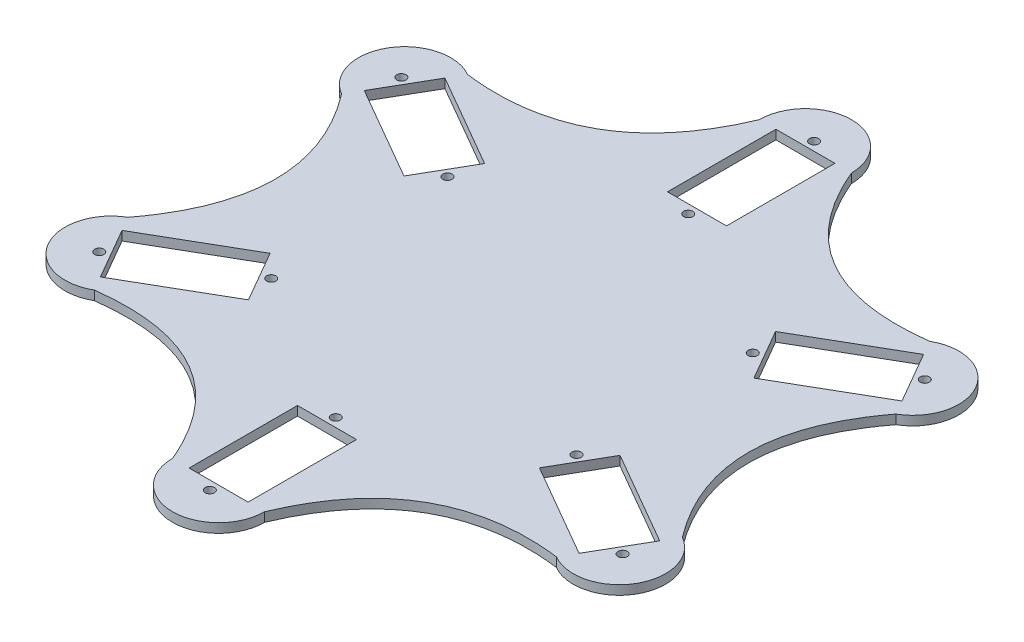
from build123d import *

# Parameters (mm, degrees)
SKETCH4_W           = 12.8
SKETCH4_H           = 23.5
SKETCH4_R           = 1
BOSS_EXTRUDE3_DEPTH = 2


with BuildPart() as part:
    # Sketch4 → Boss-Extrude3 (new body)
    with BuildSketch(Plane(origin=(0, 0, 0), x_dir=(1, 0, 0), z_dir=(0, 1, 0))):
        with BuildLine():
            ThreePointArc((10, 63.612159322), (0, 73.612159322), (-10, 63.612159322))
            add(Edge.make_bspline(
                [(-10, 63.612159322), (-21.25, 36.806079661), (-50.089745962, 40.466333699)],
                knots=[0, 0, 0, 1, 1, 1], degree=2))
            ThreePointArc((-50.089745962, 40.466333699), (-63.75, 36.806079661), (-60.089745962, 23.145825623))
            add(Edge.make_bspline(
                [(-60.089745962, 23.145825623), (-42.5, 0), (-60.089745962, -23.145825623)],
                knots=[0, 0, 0, 1, 1, 1], degree=2))
            ThreePointArc((-60.089745962, -23.145825623), (-63.75, -36.806079661), (-50.089745962, -40.466333699))
            add(Edge.make_bspline(
                [(-50.089745962, -40.466333699), (-21.25, -36.806079661), (-10, -63.612159322)],
                knots=[0, 0, 0, 1, 1, 1], degree=2))
            ThreePointArc((-10, -63.612159322), (0, -73.612159322), (10, -63.612159322))
            add(Edge.make_bspline(
                [(10, -63.612159322), (21.25, -36.806079661), (50.089745962, -40.466333699)],
                knots=[0, 0, 0, 1, 1, 1], degree=2))
            ThreePointArc((50.089745962, -40.466333699), (63.75, -36.806079661), (60.089745962, -23.145825623))
            add(Edge.make_bspline(
                [(60.089745962, -23.145825623), (42.5, 0), (60.089745962, 23.145825623)],
                knots=[0, 0, 0, 1, 1, 1], degree=2))
            ThreePointArc((60.089745962, 23.145825623), (63.75, 36.806079661), (50.089745962, 40.466333699))
            add(Edge.make_bspline(
                [(50.089745962, 40.466333699), (21.25, 36.806079661), (10, 63.612159322)],
                knots=[0, 0, 0, 1, 1, 1], degree=2))
        make_face()
        with Locations((0, 51.862159322)):
            Rectangle(SKETCH4_W, SKETCH4_H, mode=Mode.SUBTRACT)
        with Locations((0, 65.512159322)):
            Circle(SKETCH4_R, mode=Mode.SUBTRACT)
        Polygon((31.538148973, 25.598642245), (51.889745962, 37.348642245), (58.289745962, 26.263517077), (37.938148973, 14.513517077), align=None, mode=Mode.SUBTRACT)
        Polygon((37.938148973, -14.513517077), (58.289745962, -26.263517077), (51.889745962, -37.348642245), (31.538148973, -25.598642245), align=None, mode=Mode.SUBTRACT)
        with Locations((0, -51.862159322)):
            Rectangle(SKETCH4_W, SKETCH4_H, mode=Mode.SUBTRACT)
        Polygon((-31.538148973, -25.598642245), (-51.889745962, -37.348642245), (-58.289745962, -26.263517077), (-37.938148973, -14.513517077), align=None, mode=Mode.SUBTRACT)
        Polygon((-37.938148973, 14.513517077), (-58.289745962, 26.263517077), (-51.889745962, 37.348642245), (-31.538148973, 25.598642245), align=None, mode=Mode.SUBTRACT)
        with Locations((33.092700706, 19.106079661)):
            Circle(SKETCH4_R, mode=Mode.SUBTRACT)
        with Locations((0, 38.212159322)):
            Circle(SKETCH4_R, mode=Mode.SUBTRACT)
        with Locations((-33.092700706, -19.106079661)):
            Circle(SKETCH4_R, mode=Mode.SUBTRACT)
        with Locations((0, -38.212159322)):
            Circle(SKETCH4_R, mode=Mode.SUBTRACT)
        with Locations((33.092700706, -19.106079661)):
            Circle(SKETCH4_R, mode=Mode.SUBTRACT)
        with Locations((-33.092700706, 19.106079661)):
            Circle(SKETCH4_R, mode=Mode.SUBTRACT)
        with Locations((56.735194229, 32.756079661)):
            Circle(SKETCH4_R, mode=Mode.SUBTRACT)
        with Locations((56.735194229, -32.756079661)):
            Circle(SKETCH4_R, mode=Mode.SUBTRACT)
        with Locations((0, -65.512159322)):
            Circle(SKETCH4_R, mode=Mode.SUBTRACT)
        with Locations((-56.735194229, -32.756079661)):
            Circle(SKETCH4_R, mode=Mode.SUBTRACT)
        with Locations((-56.735194229, 32.756079661)):
            Circle(SKETCH4_R, mode=Mode.SUBTRACT)
    extrude(amount=BOSS_EXTRUDE3_DEPTH)


solid = part.part
